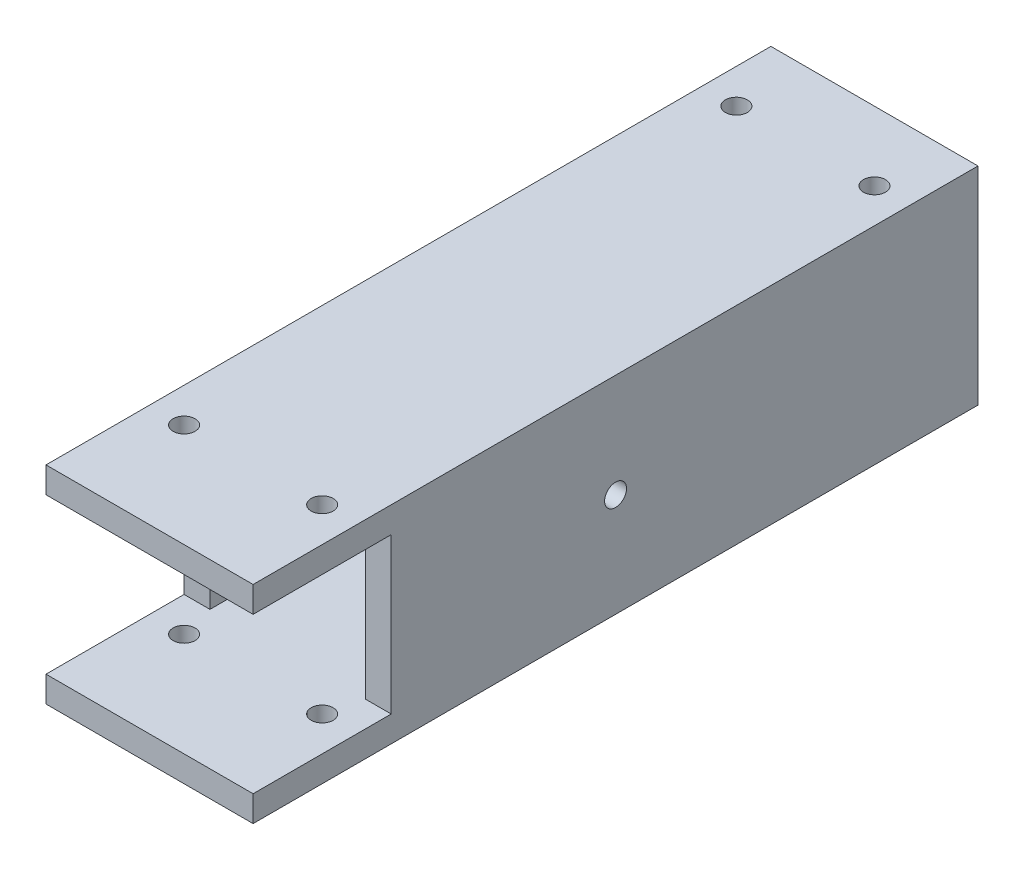
from build123d import *

# Parameters (mm, degrees)
SKETCH1_W                       = 38.1
SKETCH1_H                       = 133.35
BOSS_EXTRUDE1_DEPTH             = 19.05
SKETCH2_W                       = 28.575
SKETCH2_H                       = 28.575
CUT_EXTRUDE1_DEPTH              = 134.35
SKETCH3_W                       = 25.4
SKETCH3_H                       = 28.575
CUT_EXTRUDE2_DEPTH              = 39.1
F_10_32_TAPPED_HOLE1_AT_2_COUNT = 2
F_10_32_TAPPED_HOLE1_AT_2_PITCH = 25.4
F_10_32_TAPPED_HOLE1_AT_3_COUNT = 2
F_10_32_TAPPED_HOLE1_AT_3_PITCH = 101.6
F_10_32_TAPPED_HOLE1_AT_4_COUNT = 2
F_10_32_TAPPED_HOLE1_AT_4_PITCH = 104.726882891
F_10_32_TAPPED_HOLE2_D          = 4.0386


with BuildPart() as part:
    # Sketch1 → Boss-Extrude1 (new body, symmetric)
    with BuildSketch(Plane(origin=(0, 0, 0), x_dir=(1, 0, 0), z_dir=(0, 1, 0))):
        Rectangle(SKETCH1_W, SKETCH1_H)
    extrude(amount=BOSS_EXTRUDE1_DEPTH, both=True)

    # Sketch2 → Cut-Extrude1 (cut, through all)
    with BuildSketch(Plane.XY.offset(66.675)):
        Rectangle(SKETCH2_W, SKETCH2_H)
    extrude(amount=-CUT_EXTRUDE1_DEPTH, mode=Mode.SUBTRACT)

    # Sketch3 → Cut-Extrude2 (cut, through all)
    with BuildSketch(Plane(origin=(19.05, 0, 0), x_dir=(0, 0, -1), z_dir=(1, 0, 0))):
        with Locations((-53.975, 0)):
            Rectangle(SKETCH3_W, SKETCH3_H)
    extrude(amount=-CUT_EXTRUDE2_DEPTH, mode=Mode.SUBTRACT)

    # Sketch4 → #10-32 Tapped Hole1 (revolve, cut)
    with BuildSketch(Plane(origin=(-12.7, 19.05, 47.625), x_dir=(0, 0, 1), z_dir=(1, 0, 0))):
        Polygon((0, 0), (0, 12.389317848), (2.0193, 11.176), (2.0193, 0), align=None)
    f_10_32_tapped_hole1 = revolve(axis=Axis((-12.7, 25.4, 47.625), (0, -1, 0)), mode=Mode.SUBTRACT)

    # #10-32 Tapped Hole1 at 2: #10-32 Tapped Hole1 ×2
    with Locations(*[(i * F_10_32_TAPPED_HOLE1_AT_2_PITCH, 0, 0) for i in range(1, F_10_32_TAPPED_HOLE1_AT_2_COUNT)]):
        add(f_10_32_tapped_hole1, mode=Mode.SUBTRACT)

    # #10-32 Tapped Hole1 at 3: #10-32 Tapped Hole1 ×2
    with Locations(*[(0, 0, -i * F_10_32_TAPPED_HOLE1_AT_3_PITCH) for i in range(1, F_10_32_TAPPED_HOLE1_AT_3_COUNT)]):
        add(f_10_32_tapped_hole1, mode=Mode.SUBTRACT)

    # #10-32 Tapped Hole1 at 4: #10-32 Tapped Hole1 ×2
    with Locations(*[Vector(0.242535625, 0, -0.9701425) * (i * F_10_32_TAPPED_HOLE1_AT_4_PITCH) for i in range(1, F_10_32_TAPPED_HOLE1_AT_4_COUNT)]):
        add(f_10_32_tapped_hole1, mode=Mode.SUBTRACT)

    # #10-32 Tapped Hole2 (through all)
    with Locations(Plane(origin=(19.05, 0, 0), x_dir=(0, 0, -1), z_dir=(1, 0, 0))):
        with Locations((0, 0)):
            Hole(F_10_32_TAPPED_HOLE2_D / 2)

    # Mirror1: #10-32 Tapped Hole1 across plane
    add(f_10_32_tapped_hole1.mirror(Plane.ZX), mode=Mode.SUBTRACT)

    # Mirror1 copy 1 sketch → Mirror1 copy 1 (revolve, cut)
    with BuildSketch(Plane(origin=(12.7, -19.05, 47.625), x_dir=(0, 0, 1), z_dir=(1, 0, 0))):
        Polygon((0, 0), (0, -12.389317848), (2.0193, -11.176), (2.0193, 0), align=None)
    revolve(axis=Axis((12.7, -25.4, 47.625), (0, -1, 0)), mode=Mode.SUBTRACT)

    # Mirror1 copy 2 sketch → Mirror1 copy 2 (revolve, cut)
    with BuildSketch(Plane(origin=(-12.7, -19.05, -53.975), x_dir=(0, 0, 1), z_dir=(1, 0, 0))):
        Polygon((0, 0), (0, -12.389317848), (2.0193, -11.176), (2.0193, 0), align=None)
    revolve(axis=Axis((-12.7, -25.4, -53.975), (0, -1, 0)), mode=Mode.SUBTRACT)

    # Mirror1 copy 3 sketch → Mirror1 copy 3 (revolve, cut)
    with BuildSketch(Plane(origin=(12.7, -19.05, -53.975), x_dir=(0, 0, 1), z_dir=(1, 0, 0))):
        Polygon((0, 0), (0, -12.389317848), (2.0193, -11.176), (2.0193, 0), align=None)
    revolve(axis=Axis((12.7, -25.4, -53.975), (0, -1, 0)), mode=Mode.SUBTRACT)


solid = part.part
